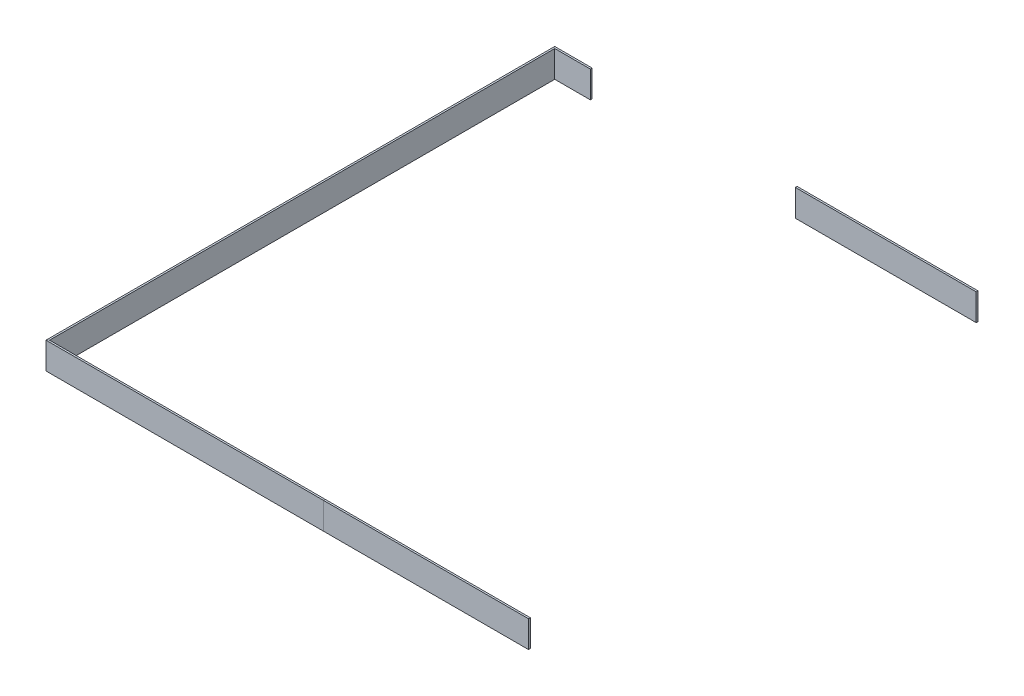
from build123d import *

# Parameters (mm, degrees)
SKETCH2_W     = 1.27
SKETCH2_H     = 19.05
SKETCH4_W     = 42.2402
SKETCH4_H     = 30.583151246
SKETCH4_W_2   = 146.177
SKETCH4_H_2   = 37.281519526
NOTCHES_DEPTH = 5.08


with BuildPart() as part:
    # L-Bracket: sweep along a path in Sketch3
    with BuildLine(Plane(origin=(0, 0, 0), x_dir=(1, 0, 0), z_dir=(0, 1, 0))) as l_bracket_path:
        Line((0, 0), (-342.9, 0))
        Line((-342.9, 0), (-342.9, -360.3625))
        Line((-342.9, -360.3625), (-146.05, -360.3625))
        Line((-146.05, -360.3625), (0, -360.3625))
    # Sketch2 → L-Bracket (sweep)
    with BuildSketch(Plane(origin=(0, 0, 0), x_dir=(0, 0, -1), z_dir=(1, 0, 0))):
        with Locations((0.635, 9.525)):
            Rectangle(SKETCH2_W, SKETCH2_H)
    sweep(path=l_bracket_path.line, transition=Transition.RIGHT)

    # Sketch4 → Notches (cut)
    with BuildSketch(Plane(origin=(0, 0, -1.27), x_dir=(-1, 0, 0), z_dir=(0, 0, -1))):
        with Locations((21.1201, 12.159570772)):
            Rectangle(SKETCH4_W, SKETCH4_H)
        with Locations((244.4115, 11.857544077)):
            Rectangle(SKETCH4_W_2, SKETCH4_H_2)
    extrude(amount=-NOTCHES_DEPTH, mode=Mode.SUBTRACT)


solid = part.part
